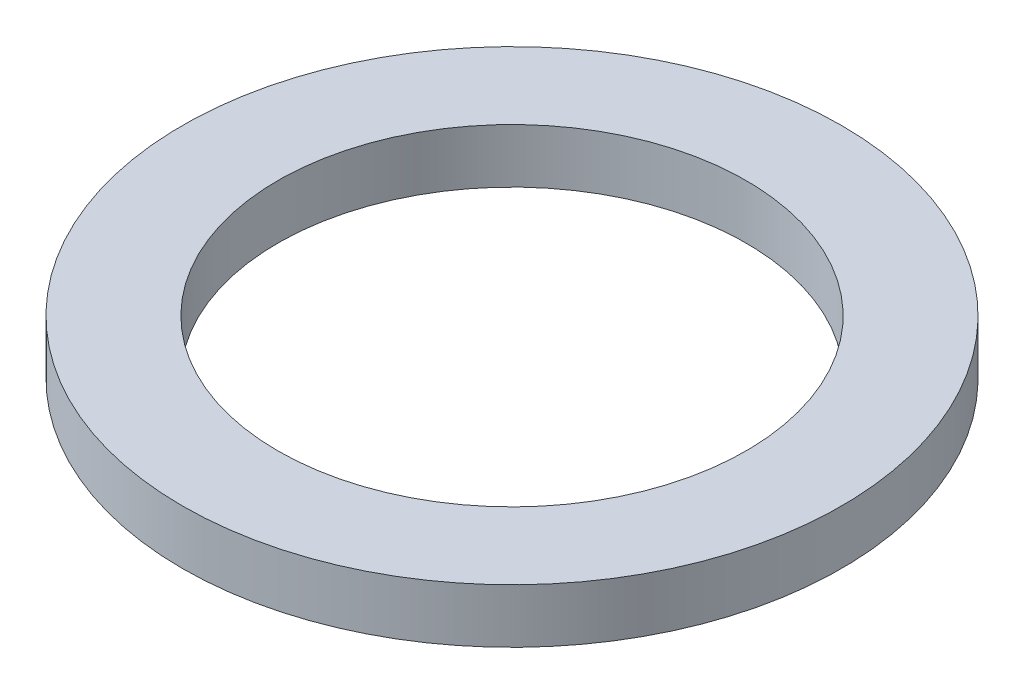
from build123d import *

# Parameters (mm, degrees)
SKETCH1_R           = 4.826
SKETCH1_R_2         = 3.429
BOSS_EXTRUDE1_DEPTH = 0.79375


with BuildPart() as part:
    # Sketch1 → Boss-Extrude1 (new body)
    with BuildSketch(Plane(origin=(0, 0, 0), x_dir=(1, 0, 0), z_dir=(0, 1, 0))):
        Circle(SKETCH1_R)
        Circle(SKETCH1_R_2, mode=Mode.SUBTRACT)
    extrude(amount=BOSS_EXTRUDE1_DEPTH)


solid = part.part
